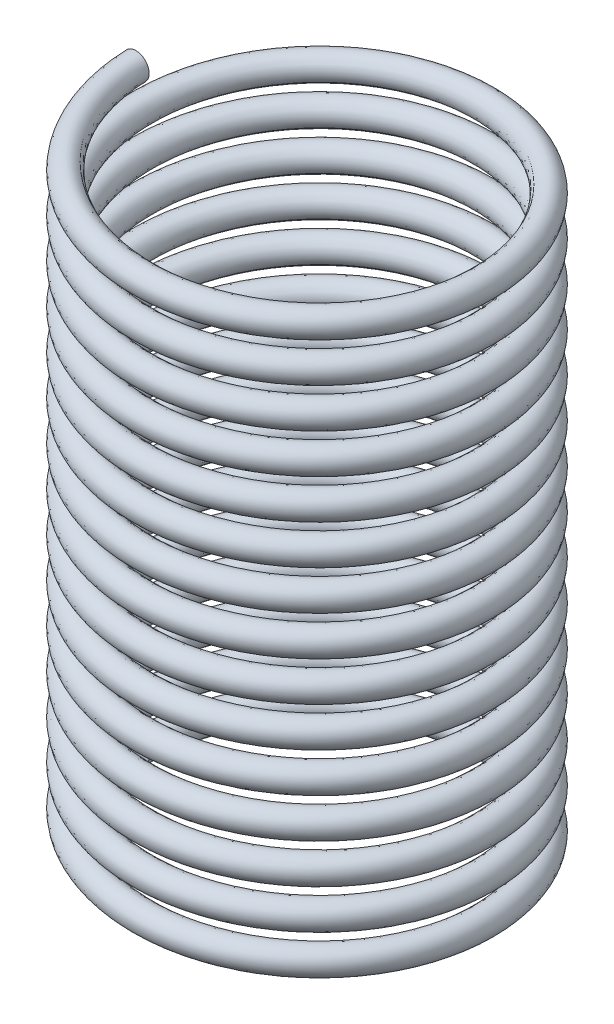
from build123d import *

# Parameters (mm, degrees)
SWEEP_1_PITCH       = 3
SWEEP_1_HEIGHT      = 45
SWEEP_1_RADIUS      = 13
SWEEP_1_START_ANGLE = -90
SKETCH_5_R          = 1


with BuildPart() as part:
    # 扫描1: sweep along a helix
    with BuildLine() as sweep_1_path:
        add(Helix(SWEEP_1_PITCH, SWEEP_1_HEIGHT, SWEEP_1_RADIUS, center=(0, 0, 0), direction=(0, 1, 0), lefthand=True, mode=Mode.PRIVATE).rotate(Axis((0, 0, 0), (0, 1, 0)), SWEEP_1_START_ANGLE))
    # 草图5 → 扫描1 (sweep)
    with BuildSketch(Plane.XY):
        with Locations((-13, 45)):
            Circle(SKETCH_5_R)
    sweep(path=sweep_1_path.line, is_frenet=True)


solid = part.part
